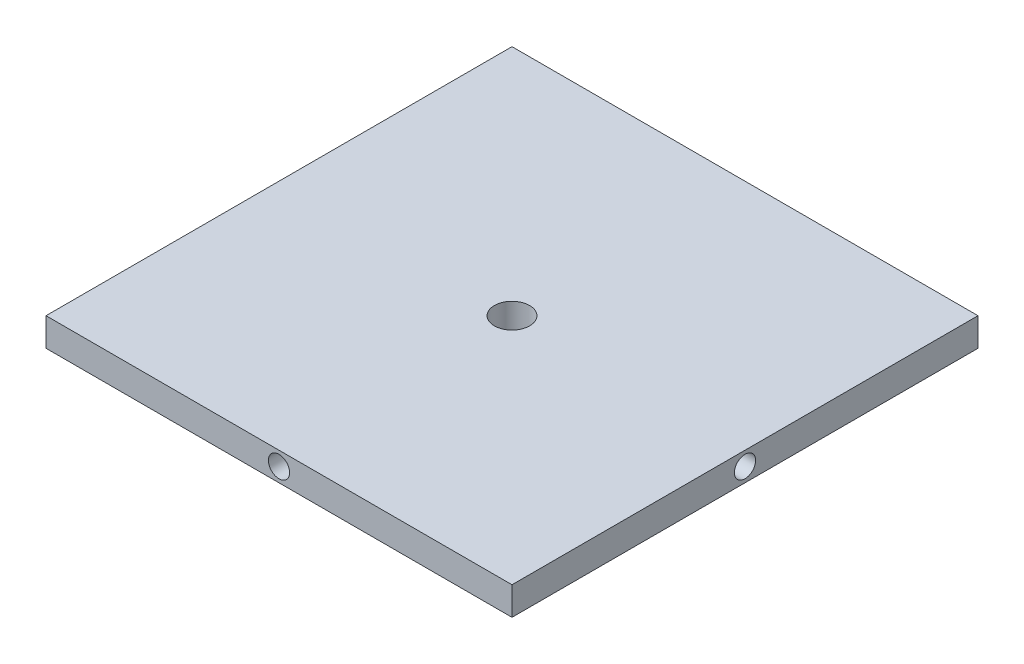
from build123d import *

# Parameters (mm, degrees)
SKETCH1_W                       = 419.1
SKETCH1_H                       = 419.1
SKETCH1_R                       = 15.875
BOSS_EXTRUDE1_DEPTH             = 25.4
F_3_4_0_75_DIAMETER_HOLE2_D     = 19.05
F_3_4_0_75_DIAMETER_HOLE2_DEPTH = 76.2
F_3_4_0_75_DIAMETER_HOLE2_TIP   = 5.723197396
F_3_4_0_75_DIAMETER_HOLE1_D     = 19.05
F_3_4_0_75_DIAMETER_HOLE1_DEPTH = 76.2
F_3_4_0_75_DIAMETER_HOLE1_TIP   = 5.723197396


with BuildPart() as part:
    # Sketch1 → Boss-Extrude1 (new body)
    with BuildSketch(Plane(origin=(0, 0, 0), x_dir=(1, 0, 0), z_dir=(0, 1, 0))):
        Rectangle(SKETCH1_W, SKETCH1_H)
        Circle(SKETCH1_R, mode=Mode.SUBTRACT)
    extrude(amount=BOSS_EXTRUDE1_DEPTH)

    # 3_4 _0.75_ Diameter Hole2
    with Locations(Plane(origin=(209.55, 0, 0), x_dir=(0, 0, -1), z_dir=(1, 0, 0))):
        with Locations((0, 12.7)):
            Hole(F_3_4_0_75_DIAMETER_HOLE2_D / 2, depth=F_3_4_0_75_DIAMETER_HOLE2_DEPTH)
            with Locations((0, 0, -(F_3_4_0_75_DIAMETER_HOLE2_DEPTH + F_3_4_0_75_DIAMETER_HOLE2_TIP / 2))):  # 118° drill point
                Cone(0, F_3_4_0_75_DIAMETER_HOLE2_D / 2, F_3_4_0_75_DIAMETER_HOLE2_TIP, mode=Mode.SUBTRACT)

    # 3_4 _0.75_ Diameter Hole1
    with Locations(Plane.XY.offset(209.55)):
        with Locations((0, 12.7)):
            Hole(F_3_4_0_75_DIAMETER_HOLE1_D / 2, depth=F_3_4_0_75_DIAMETER_HOLE1_DEPTH)
            with Locations((0, 0, -(F_3_4_0_75_DIAMETER_HOLE1_DEPTH + F_3_4_0_75_DIAMETER_HOLE1_TIP / 2))):  # 118° drill point
                Cone(0, F_3_4_0_75_DIAMETER_HOLE1_D / 2, F_3_4_0_75_DIAMETER_HOLE1_TIP, mode=Mode.SUBTRACT)


solid = part.part
